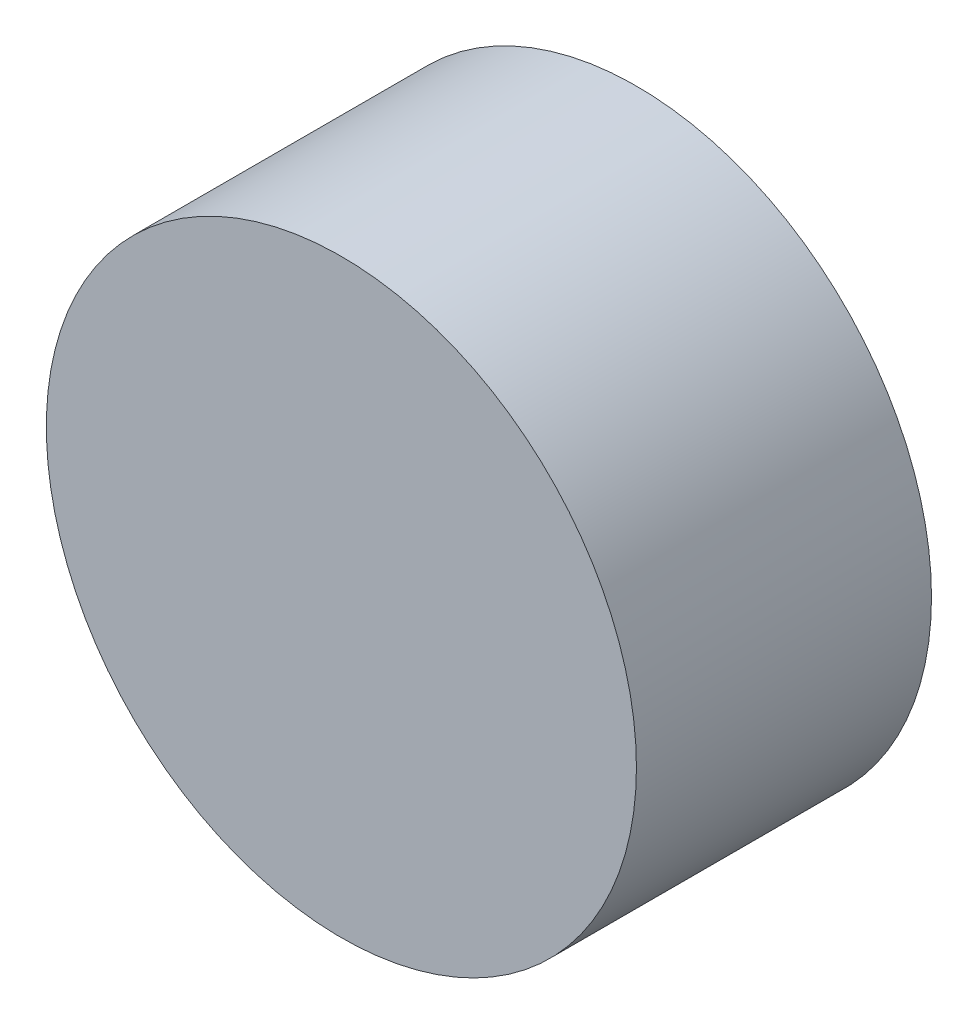
from build123d import *

# Parameters (mm, degrees)
CROQUIS1_R              = 10
SALIENTE_EXTRUIR1_DEPTH = 10


with BuildPart() as part:
    # Croquis1 → Saliente-Extruir1 (new body)
    with BuildSketch(Plane.XY):
        with Locations((-2.705955996, 4.516104641)):
            Circle(CROQUIS1_R)
    extrude(amount=SALIENTE_EXTRUIR1_DEPTH)


solid = part.part
